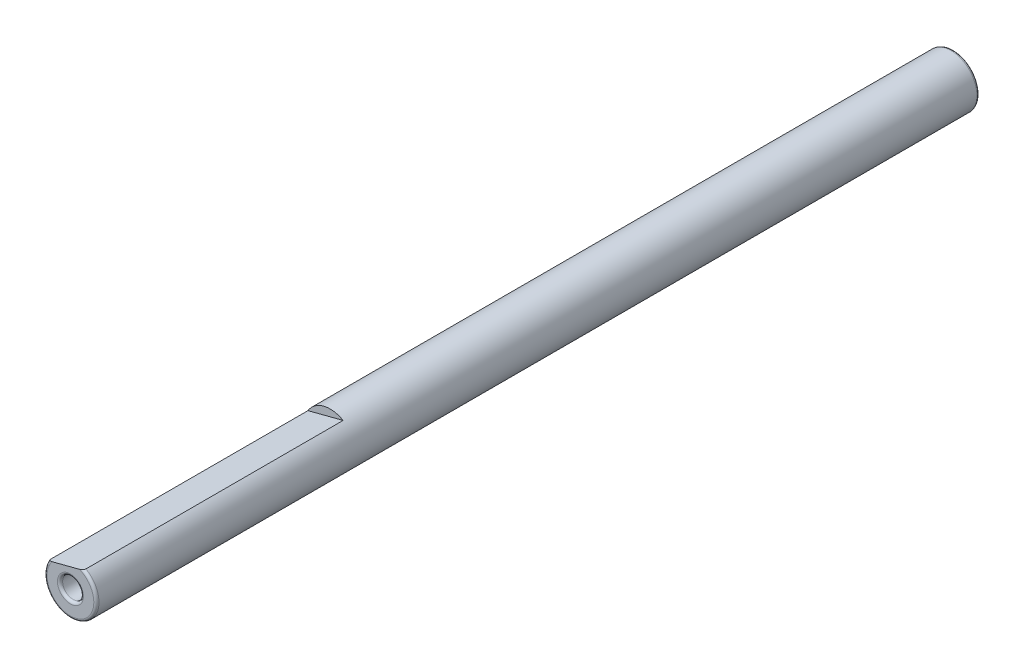
from build123d import *

# Parameters (mm, degrees)
CROQUIS1_R              = 2.5
SALIENTE_EXTRUIR1_DEPTH = 85
CROQUIS2_R              = 1
CORTAR_EXTRUIR1_DEPTH   = 86
REDONDEO1_R             = 0.25
ENL_V_MAT_EXTRU_1_DEPTH = 25


with BuildPart() as part:
    # Croquis1 → Saliente-Extruir1 (new body)
    with BuildSketch(Plane.XY):
        Circle(CROQUIS1_R)
    extrude(amount=SALIENTE_EXTRUIR1_DEPTH)

    # Croquis2 → Cortar-Extruir1 (cut, through all)
    with BuildSketch(Plane.XY.offset(85)):
        Circle(CROQUIS2_R)
    extrude(amount=-CORTAR_EXTRUIR1_DEPTH, mode=Mode.SUBTRACT)

    # Redondeo1
    redondeo1_edges = [part.edges().sort_by_distance(p)[0] for p in [
        (-2.5, 0, 0),
        (-2.5, 0, 85),
        (-1, 0, 85),
    ]]
    fillet(redondeo1_edges, radius=REDONDEO1_R)

    # Esquisse1 → Enlèv. mat.-Extru.1 (cut)
    with BuildSketch(Plane.XY.offset(85)):
        with BuildLine():
            Line((-2.141675568, 1.289661103), (1.246569633, 2.167040413))
            ThreePointArc((1.246569633, 2.167040413), (-0.626699507, 2.420175144), (-2.141675568, 1.289661103))
        make_face()
    extrude(amount=-ENL_V_MAT_EXTRU_1_DEPTH, mode=Mode.SUBTRACT)


solid = part.part
